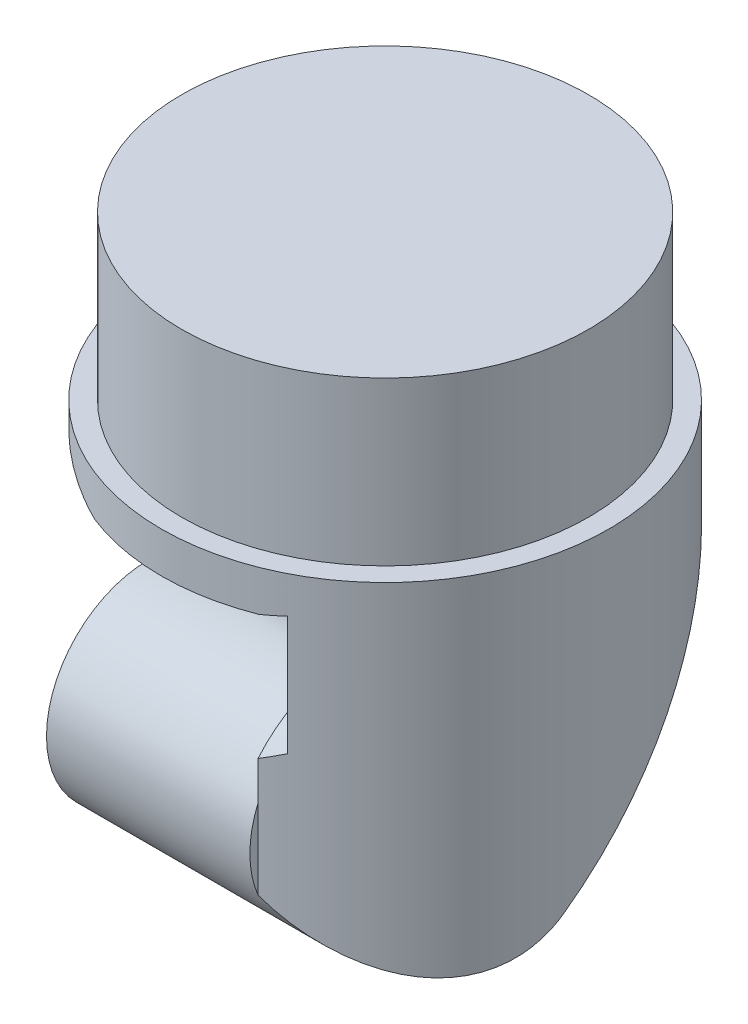
from build123d import *

# Parameters (mm, degrees)
SKETCH1_W               = 11
SKETCH1_H               = 11
BOSS_EXTRUDE1_DEPTH     = 15
SKETCH2_R               = 11.526525906
SKETCH2_R_2             = 5
CUT_EXTRUDE1_DEPTH      = 4
SKETCH3_R               = 9.335544837
SKETCH3_R_2             = 5.5
CUT_EXTRUDE2_DEPTH      = 1
CUT_EXTRUDE4_DEPTH      = 20.397164741
CUT_EXTRUDE5_DEPTH      = 7.5
SKETCH7_R               = 4.206819523
CUT_EXTRUDE6_DEPTH      = 2.5
SKETCH8_R               = 8.743774997
CUT_EXTRUDE7_DEPTH      = 12.521718622
SKETCH9_R               = 5.5
SKETCH9_R_2             = 2.5
CUT_EXTRUDE8_DEPTH      = 5
CUT_EXTRUDE8_DEPTH_BACK = 5
CUT_EXTRUDE9_DEPTH      = 0.5


with BuildPart() as part:
    # Sketch1 → Boss-Extrude1 (new body)
    with BuildSketch(Plane(origin=(0, 0, 0), x_dir=(1, 0, 0), z_dir=(0, 1, 0))):
        Rectangle(SKETCH1_W, SKETCH1_H)
    extrude(amount=BOSS_EXTRUDE1_DEPTH)

    # Sketch2 → Cut-Extrude1 (cut)
    with BuildSketch(Plane(origin=(0, 15, 0), x_dir=(1, 0, 0), z_dir=(0, 1, 0))):
        Circle(SKETCH2_R)
        with Locations(Location((0, 0, 0), (0, 0, 270))):
            Circle(SKETCH2_R_2, mode=Mode.SUBTRACT)
    extrude(amount=-CUT_EXTRUDE1_DEPTH, mode=Mode.SUBTRACT)

    # Sketch3 → Cut-Extrude2 (cut)
    with BuildSketch(Plane(origin=(0, 11, 0), x_dir=(1, 0, 0), z_dir=(0, 1, 0))):
        Circle(SKETCH3_R)
        with Locations(Location((0, 0, 0), (0, 0, 270))):
            Circle(SKETCH3_R_2, mode=Mode.SUBTRACT)
    extrude(amount=-CUT_EXTRUDE2_DEPTH, mode=Mode.SUBTRACT)

    # Sketch4 → Cut-Extrude4 (cut, through all)
    with BuildSketch(Plane.ZY.offset(5.5)):
        with BuildLine():
            Line((1.028660662, 3.260538449), (-5.5, 10))
            Line((-5.5, 10), (-9.452355575, 12.560239237))
            Line((-9.452355575, 12.560239237), (-9.996263861, -3.051690792))
            Line((-9.996263861, -3.051690792), (13.077304092, -2.572417867))
            Line((13.077304092, -2.572417867), (11.793537329, 10))
            Line((11.793537329, 10), (5.5, 10))
            Line((5.5, 10), (5.32277104, 4.912954629))
            ThreePointArc((5.32277104, 4.912954629), (3.722129922, 2.666788079), (1.028660662, 3.260538449))
        make_face()
    extrude(amount=-CUT_EXTRUDE4_DEPTH, mode=Mode.SUBTRACT)

    # Sketch6 → Cut-Extrude5 (cut)
    with BuildSketch(Plane.ZY.offset(5.5)):
        with BuildLine():
            Line((5.32277104, 4.912954629), (5.5, 10))
            Line((5.5, 10), (-5.5, 10))
            Line((-5.5, 10), (1.028660662, 3.260538449))
            ThreePointArc((1.028660662, 3.260538449), (1.926443835, 7.333211921), (5.32277104, 4.912954629))
        make_face()
    extrude(amount=-CUT_EXTRUDE5_DEPTH, mode=Mode.SUBTRACT)

    # Sketch7 → Cut-Extrude6 (cut)
    with BuildSketch(Plane.ZY.offset(5.5)):
        with Locations((2.824286879, 5)):
            Circle(SKETCH7_R)
    extrude(amount=-CUT_EXTRUDE6_DEPTH, mode=Mode.SUBTRACT)

    # Sketch8 → Cut-Extrude7 (cut, through all)
    with BuildSketch(Plane(origin=(0, 11, 0), x_dir=(1, 0, 0), z_dir=(0, 1, 0))):
        Circle(SKETCH8_R)
        with BuildLine():
            Line((0, -5.5), (2, -5.5))
            Line((2, -5.5), (2, -5.123475383))
            ThreePointArc((2, -5.123475383), (0.790050421, 5.442960622), (-3.374127459, -4.343416154))
            Line((-3.374127459, -4.343416154), (-3.374127459, -5.5))
            Line((-3.374127459, -5.5), (0, -5.5))
        make_face(mode=Mode.SUBTRACT)
    extrude(amount=-CUT_EXTRUDE7_DEPTH, mode=Mode.SUBTRACT)

    # Sketch9 → Cut-Extrude8 (cut, two sides)
    with BuildSketch(Plane.ZY.offset(3)) as cut_extrude8_sk:
        with Locations((2.824286879, 5)):
            Circle(SKETCH9_R)
        with Locations((2.824286879, 5)):
            Circle(SKETCH9_R_2, mode=Mode.SUBTRACT)
    extrude(amount=CUT_EXTRUDE8_DEPTH, mode=Mode.SUBTRACT)
    extrude(cut_extrude8_sk.sketch, amount=-CUT_EXTRUDE8_DEPTH_BACK, mode=Mode.SUBTRACT)

    # Sketch10 → Cut-Extrude9 (cut)
    with BuildSketch(Plane.ZY.offset(-2)):
        with BuildLine():
            ThreePointArc((-0.125167599, 4.451622134), (1.544554545, 7.71335312), (5.123475383, 6.927104621))
            Line((5.123475383, 6.927104621), (5.123475383, 9.996371906))
            ThreePointArc((5.123475383, 9.996371906), (5.119525771, 9.998187514), (5.115574726, 10))
            ThreePointArc((5.115574726, 10), (2.824286879, 10.5), (0.532999031, 10))
            Line((0.532999031, 10), (-5.123475383, 10))
            Line((-5.123475383, 10), (-5.123475383, 9.611317955))
            Line((-5.123475383, 9.611317955), (-2.379973921, 6.779232849))
            Line((-2.379973921, 6.779232849), (-0.125167599, 4.451622134))
        make_face()
    extrude(amount=-CUT_EXTRUDE9_DEPTH, mode=Mode.SUBTRACT)


solid = part.part
